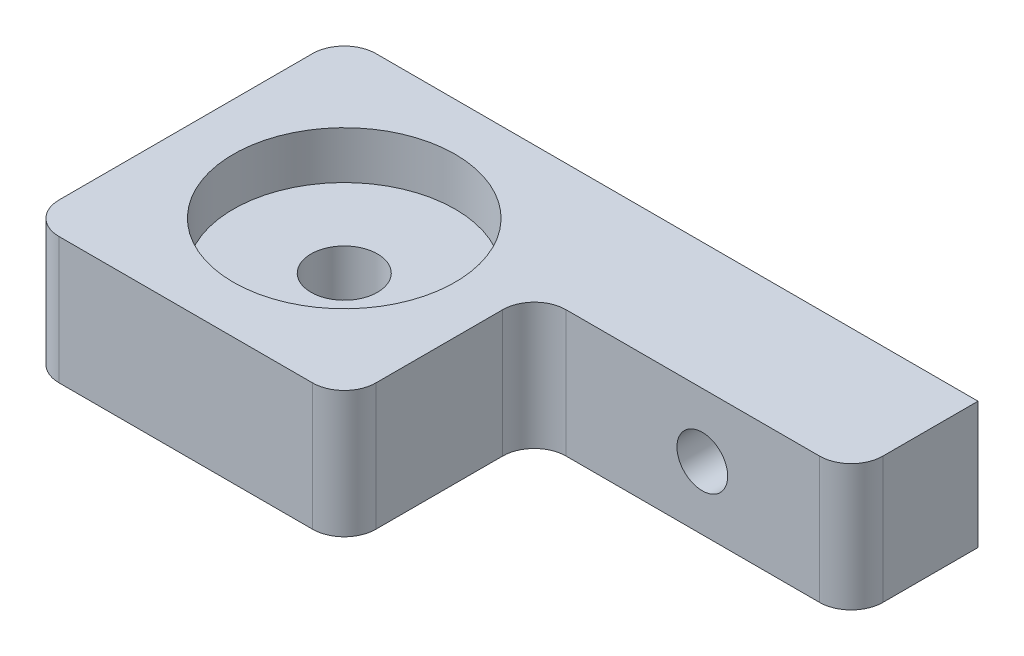
from build123d import *

# Parameters (mm, degrees)
ESQUISSE1_W             = 40
ESQUISSE1_H             = 8
BOSS_EXTRU_1_DEPTH      = 8
ESQUISSE2_W             = 20
ESQUISSE2_H             = 8
BOSS_EXTRU_2_DEPTH      = 12
CONG_1_R                = 2
ESQUISSE3_R             = 2.1
ENL_V_MAT_EXTRU_1_DEPTH = 9
ESQUISSE5_R             = 1.6
ENL_V_MAT_EXTRU_2_DEPTH = 21
ESQUISSE6_R             = 7
ENL_V_MAT_EXTRU_3_DEPTH = 3


with BuildPart() as part:
    # Esquisse1 → Boss.-Extru.1 (new body)
    with BuildSketch(Plane.XY):
        with Locations((20, 4)):
            Rectangle(ESQUISSE1_W, ESQUISSE1_H)
    extrude(amount=BOSS_EXTRU_1_DEPTH)

    # Esquisse2 → Boss.-Extru.2 (add)
    with BuildSketch(Plane.XY.offset(8)):
        with Locations((10, 4)):
            Rectangle(ESQUISSE2_W, ESQUISSE2_H)
    extrude(amount=BOSS_EXTRU_2_DEPTH)

    # Congé1
    cong_1_edges = [part.edges().sort_by_distance(p)[0] for p in [
        (0, 4, 0),
        (40, 4, 8),
        (0, 4, 20),
        (20, 4, 20),
        (20, 4, 8),
    ]]
    fillet(cong_1_edges, radius=CONG_1_R)

    # Esquisse3 → Enlèv. mat.-Extru.1 (cut, through all)
    with BuildSketch(Plane(origin=(0, 8, 0), x_dir=(1, 0, 0), z_dir=(0, 1, 0))):
        with Locations((10, -10)):
            Circle(ESQUISSE3_R)
    extrude(amount=-ENL_V_MAT_EXTRU_1_DEPTH, mode=Mode.SUBTRACT)

    # Esquisse5 → Enlèv. mat.-Extru.2 (cut, through all)
    with BuildSketch(Plane(origin=(0, 0, 0), x_dir=(-1, 0, 0), z_dir=(0, 0, -1))):
        with Locations((-30.6, 4)):
            Circle(ESQUISSE5_R)
    extrude(amount=-ENL_V_MAT_EXTRU_2_DEPTH, mode=Mode.SUBTRACT)

    # Esquisse6 → Enlèv. mat.-Extru.3 (cut)
    with BuildSketch(Plane(origin=(0, 8, 0), x_dir=(1, 0, 0), z_dir=(0, 1, 0))):
        with Locations((10, -10)):
            Circle(ESQUISSE6_R)
    extrude(amount=-ENL_V_MAT_EXTRU_3_DEPTH, mode=Mode.SUBTRACT)


solid = part.part
